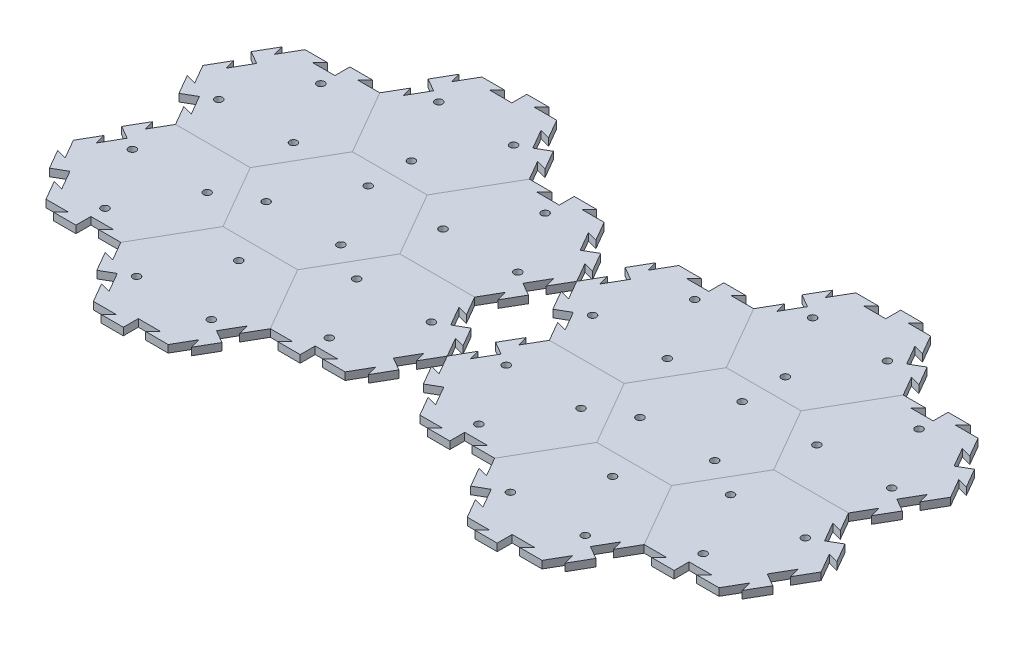
from build123d import *

# Parameters (mm, degrees)
BOSS_EXTRUDE1_DEPTH = 6.35
SKETCH9_R           = 3.175
CUT_EXTRUDE3_DEPTH  = 7.35
CIRPATTERN6_COUNT   = 3
CUT_EXTRUDE2_DEPTH  = 7.35
BOSS_EXTRUDE3_DEPTH = 6.35
CIRPATTERN3_COUNT   = 3
CIRPATTERN3_ANGLE   = 120
CIRPATTERN5_COUNT   = 6
LPATTERN1_COUNT     = 2
LPATTERN1_PITCH     = 317.5


with BuildPart() as part:
    # Sketch1 → Boss-Extrude1 (new body)
    with BuildSketch(Plane(origin=(0, 0, 0), x_dir=(1, 0, 0), z_dir=(0, 1, 0))):
        Polygon((63.5, 0), (31.75, 54.99261314), (-31.75, 54.99261314), (-63.5, 0), (-31.75, -54.99261314), (31.75, -54.99261314), align=None)
    extrude(amount=-BOSS_EXTRUDE1_DEPTH)

    # Sketch9 → Cut-Extrude3 (cut, through all)
    with BuildSketch(Plane(origin=(0, 0, 0), x_dir=(1, 0, 0), z_dir=(0, 1, 0))):
        with Locations((-31.75, -18.330871047)):
            Circle(SKETCH9_R)
    cut_extrude3 = extrude(amount=-CUT_EXTRUDE3_DEPTH, mode=Mode.SUBTRACT)

    # CirPattern6: Cut-Extrude3 ×3 about axis
    cirpattern6_axis = Axis((0, 0, 0), (0, 1, 0))
    for i in range(1, CIRPATTERN6_COUNT):
        add(cut_extrude3.rotate(cirpattern6_axis, i * 360 / CIRPATTERN6_COUNT), mode=Mode.SUBTRACT)


with BuildPart() as body_2:
    # Mirror1: mirrored copy
    add(part.part.mirror(Plane(origin=(31.75, -6.35, 54.99261314), x_dir=(-0.5, 0, 0.866025404), z_dir=(0.866025404, 0, 0.5))))

    # Sketch5 → Cut-Extrude2 (cut, through all)
    with BuildSketch(Plane(origin=(0, 0, 0), x_dir=(1, 0, 0), z_dir=(0, 1, 0))):
        Polygon((136.525, -16.497783942), (127.850738686, -14.173522628), (137.375738686, -30.67130657), (142.875, -27.49630657), align=None)
    cut_extrude2 = extrude(amount=-CUT_EXTRUDE2_DEPTH, mode=Mode.SUBTRACT)

    # Sketch7 → Boss-Extrude3 (add)
    with BuildSketch(Plane(origin=(0, 0, 0), x_dir=(1, 0, 0), z_dir=(0, 1, 0))):
        Polygon((142.875, -27.49630657), (148.374261314, -24.32130657), (157.899261314, -40.819090512), (149.225, -38.494829198), align=None)
    boss_extrude3 = extrude(amount=-BOSS_EXTRUDE3_DEPTH)

    # CirPattern3: Cut-Extrude2, Boss-Extrude3 ×3 about axis
    cirpattern3_axis = Axis((95.25, 0, 54.99261314), (0, -1, 0))
    for i in range(1, CIRPATTERN3_COUNT):
        add(cut_extrude2.rotate(cirpattern3_axis, i * CIRPATTERN3_ANGLE / (CIRPATTERN3_COUNT - 1)), mode=Mode.SUBTRACT)
        add(boss_extrude3.rotate(cirpattern3_axis, i * CIRPATTERN3_ANGLE / (CIRPATTERN3_COUNT - 1)))


with BuildPart() as cirpattern5_1:
    # CirPattern5: pattern copy
    add(body_2.part.rotate(Axis((0, 0, 0), (0, 1, 0)), 1 * 360 / CIRPATTERN5_COUNT))


with BuildPart() as cirpattern5_2:
    # CirPattern5: pattern copy
    add(body_2.part.rotate(Axis((0, 0, 0), (0, 1, 0)), 2 * 360 / CIRPATTERN5_COUNT))


with BuildPart() as cirpattern5_3:
    # CirPattern5: pattern copy
    add(body_2.part.rotate(Axis((0, 0, 0), (0, 1, 0)), 3 * 360 / CIRPATTERN5_COUNT))


with BuildPart() as cirpattern5_4:
    # CirPattern5: pattern copy
    add(body_2.part.rotate(Axis((0, 0, 0), (0, 1, 0)), 4 * 360 / CIRPATTERN5_COUNT))


with BuildPart() as cirpattern5_5:
    # CirPattern5: pattern copy
    add(body_2.part.rotate(Axis((0, 0, 0), (0, 1, 0)), 5 * 360 / CIRPATTERN5_COUNT))


with BuildPart() as lpattern1_1:
    # LPattern1: pattern copy
    add(cirpattern5_1.part.moved(Location(Vector(1, 0, 0) * (1 * LPATTERN1_PITCH))))


with BuildPart() as lpattern1_2:
    # LPattern1: pattern copy
    add(body_2.part.moved(Location(Vector(1, 0, 0) * (1 * LPATTERN1_PITCH))))


with BuildPart() as lpattern1_3:
    # LPattern1: pattern copy
    add(cirpattern5_5.part.moved(Location(Vector(1, 0, 0) * (1 * LPATTERN1_PITCH))))


with BuildPart() as lpattern1_4:
    # LPattern1: pattern copy
    add(part.part.moved(Location(Vector(1, 0, 0) * (1 * LPATTERN1_PITCH))))


with BuildPart() as lpattern1_5:
    # LPattern1: pattern copy
    add(cirpattern5_4.part.moved(Location(Vector(1, 0, 0) * (1 * LPATTERN1_PITCH))))


with BuildPart() as lpattern1_6:
    # LPattern1: pattern copy
    add(cirpattern5_2.part.moved(Location(Vector(1, 0, 0) * (1 * LPATTERN1_PITCH))))


with BuildPart() as lpattern1_7:
    # LPattern1: pattern copy
    add(cirpattern5_3.part.moved(Location(Vector(1, 0, 0) * (1 * LPATTERN1_PITCH))))


solid = Compound([part.part, body_2.part, cirpattern5_1.part, cirpattern5_2.part, cirpattern5_3.part, cirpattern5_4.part, cirpattern5_5.part, lpattern1_1.part, lpattern1_2.part, lpattern1_3.part, lpattern1_4.part, lpattern1_5.part, lpattern1_6.part, lpattern1_7.part])
